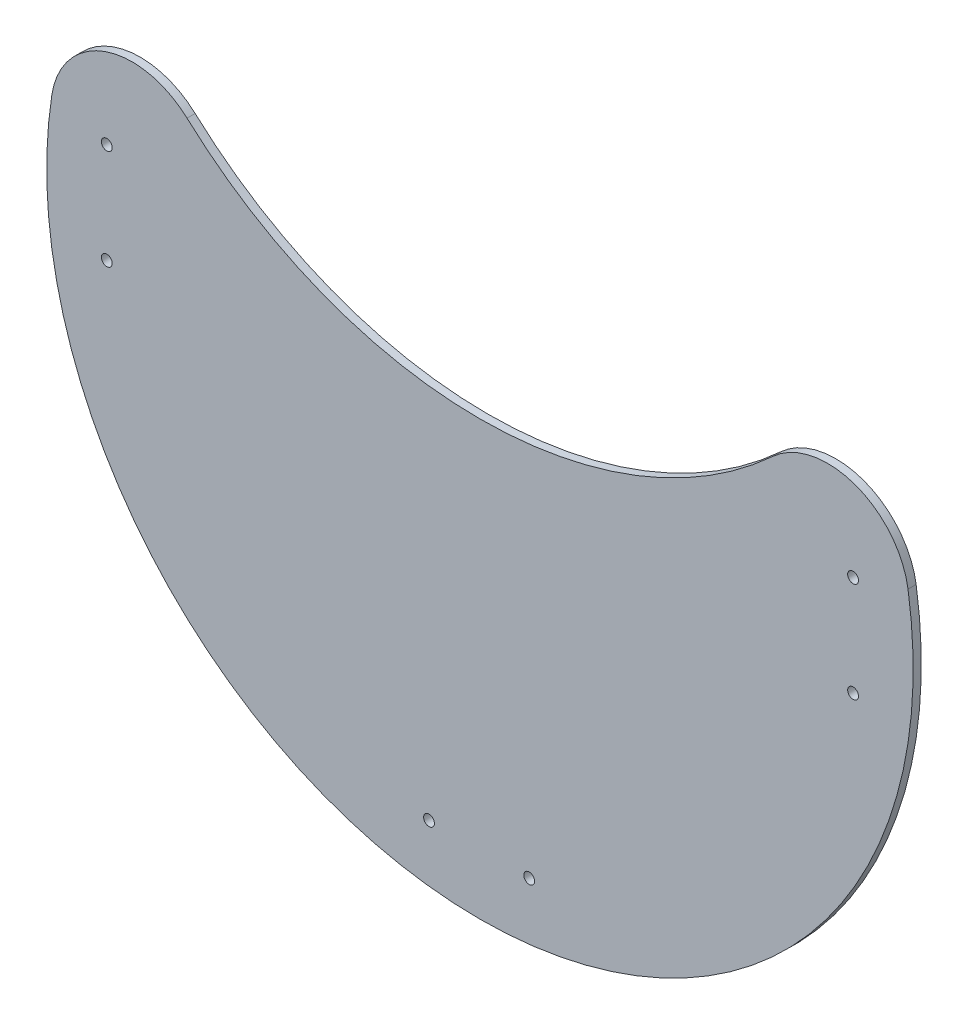
from build123d import *

# Parameters (mm, degrees)
SKETCH_1_R      = 2
EXTRUDE_1_DEPTH = 3


with BuildPart() as part:
    # 草图1 → 凸台-拉伸1 (new body)
    with BuildSketch(Plane.XY):
        with BuildLine():
            ThreePointArc((-158.095170199, 24.615384615), (0, -160), (158.095170199, 24.615384615))
            ThreePointArc((158.095170199, 24.615384615), (138.371023625, 48.312884579), (108.17037961, 42.105263158))
            ThreePointArc((108.17037961, 42.105263158), (0, 0), (-108.17037961, 42.105263158))
            ThreePointArc((-108.17037961, 42.105263158), (-138.371023625, 48.312884579), (-158.095170199, 24.615384615))
        make_face()
        with Locations((137.799674336, 18.195823561)):
            Circle(SKETCH_1_R, mode=Mode.SUBTRACT)
        with Locations((137.799674336, -18.804176439)):
            Circle(SKETCH_1_R, mode=Mode.SUBTRACT)
        with Locations((18.195823561, -137.799674336)):
            Circle(SKETCH_1_R, mode=Mode.SUBTRACT)
        with Locations((-18.804176439, -137.799674336)):
            Circle(SKETCH_1_R, mode=Mode.SUBTRACT)
        with Locations((-137.799674336, -18.195823561)):
            Circle(SKETCH_1_R, mode=Mode.SUBTRACT)
        with Locations((-137.799674336, 18.804176439)):
            Circle(SKETCH_1_R, mode=Mode.SUBTRACT)
    extrude(amount=EXTRUDE_1_DEPTH)


solid = part.part
